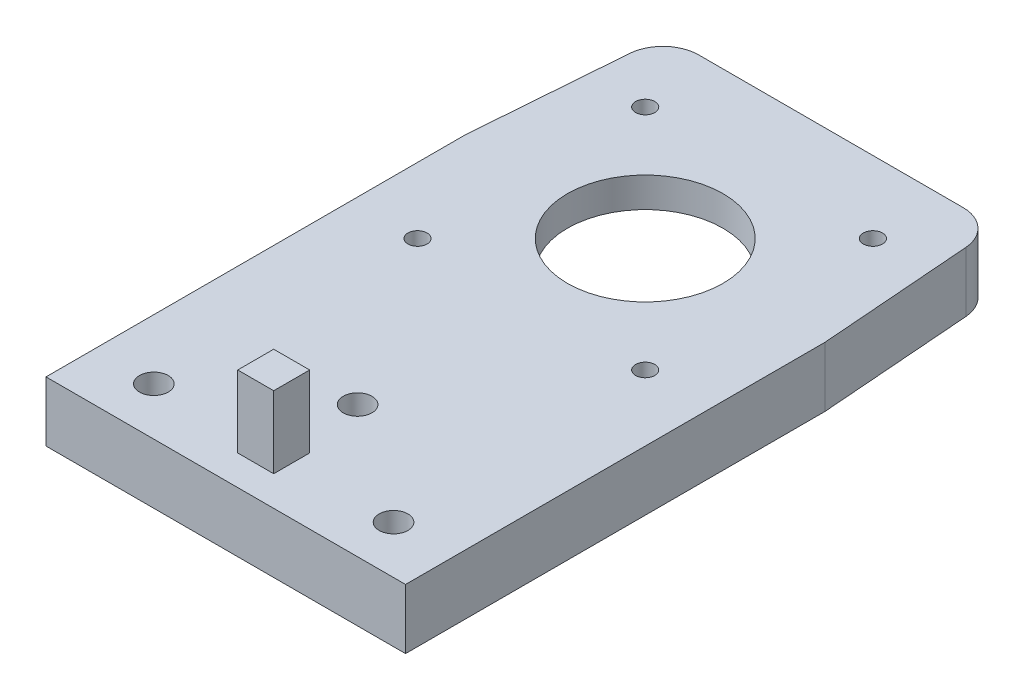
from build123d import *

# Parameters (mm, degrees)
BOSS_EXTRUDE1_DEPTH                                 = 5
CUT_EXTRUDE1_REACH                                  = 7
SKETCH2_R                                           = 6.4897
SKETCH3_W                                           = 3
SKETCH3_H                                           = 3
BOSS_EXTRUDE2_DEPTH                                 = 6
CSK_FOR_M2_COUNTERSUNK_FLAT_HEAD_SCREW1_D           = 2.4
CSK_FOR_M2_COUNTERSUNK_FLAT_HEAD_SCREW1_DEPTH       = 5.2
CSK_FOR_M2_COUNTERSUNK_FLAT_HEAD_SCREW1_CSINK_D     = 5.4
CSK_FOR_M2_COUNTERSUNK_FLAT_HEAD_SCREW1_CSINK_ANGLE = 90
CSK_FOR_M2_COUNTERSUNK_FLAT_HEAD_SCREW1_TIP         = 0.721032743
CUT_EXTRUDE2_DEPTH                                  = 2.5
FILLET1_R                                           = 3
M2_TAPPED_HOLE1_D                                   = 1.6
M2_TAPPED_HOLE1_DEPTH                               = 2.5


with BuildPart() as part:
    # Sketch1 → Boss-Extrude1 (new body)
    with BuildSketch(Plane(origin=(0, 0, 0), x_dir=(1, 0, 0), z_dir=(0, 1, 0))):
        Polygon((-15, 0), (15, 0), (15, 35), (13.807692308, 50.5), (-13.807692308, 50.5), (-15, 35), align=None)
    extrude(amount=BOSS_EXTRUDE1_DEPTH)

    # Sketch2 → Cut-Extrude1 (cut, up to next)
    with BuildSketch(Plane(origin=(0, 5, 0), x_dir=(1, 0, 0), z_dir=(0, 1, 0)), mode=Mode.PRIVATE) as cut_extrude1_sk1:
        with Locations((0, 35)):
            Circle(SKETCH2_R)
    cut_extrude1_tool1 = extrude(cut_extrude1_sk1.sketch, amount=-CUT_EXTRUDE1_REACH, mode=Mode.PRIVATE) & part.part
    add(cut_extrude1_tool1.solids().sort_by_distance((0, 5, -35))[0], mode=Mode.SUBTRACT)

    # Sketch3 → Boss-Extrude2 (add)
    with BuildSketch(Plane(origin=(0, 5, 0), x_dir=(1, 0, 0), z_dir=(0, 1, 0))):
        with Locations((0, 4)):
            Rectangle(SKETCH3_W, SKETCH3_H)
    extrude(amount=BOSS_EXTRUDE2_DEPTH)

    # CSK for M2 Countersunk Flat Head Screw1
    with Locations(Plane(origin=(0, 0, 0), x_dir=(-1, 0, 0), z_dir=(0, -1, 0))):
        with Locations((-10, 4), (10, 4), (0, 11)):
            CounterSinkHole(CSK_FOR_M2_COUNTERSUNK_FLAT_HEAD_SCREW1_D / 2, CSK_FOR_M2_COUNTERSUNK_FLAT_HEAD_SCREW1_CSINK_D / 2, depth=CSK_FOR_M2_COUNTERSUNK_FLAT_HEAD_SCREW1_DEPTH, counter_sink_angle=CSK_FOR_M2_COUNTERSUNK_FLAT_HEAD_SCREW1_CSINK_ANGLE)
            with Locations((0, 0, -(CSK_FOR_M2_COUNTERSUNK_FLAT_HEAD_SCREW1_DEPTH + CSK_FOR_M2_COUNTERSUNK_FLAT_HEAD_SCREW1_TIP / 2))):  # 118° drill point
                Cone(0, CSK_FOR_M2_COUNTERSUNK_FLAT_HEAD_SCREW1_D / 2, CSK_FOR_M2_COUNTERSUNK_FLAT_HEAD_SCREW1_TIP, mode=Mode.SUBTRACT)

    # Sketch6 → Cut-Extrude2 (cut)
    with BuildSketch(Plane.XZ):
        with BuildLine():
            Line((-10.5, -48), (10.5, -48))
            ThreePointArc((10.5, -48), (12.267766953, -47.267766953), (13, -45.5))
            Line((13, -45.5), (13, -24.5))
            ThreePointArc((13, -24.5), (12.267766953, -22.732233047), (10.5, -22))
            Line((10.5, -22), (-10.5, -22))
            ThreePointArc((-10.5, -22), (-12.267766953, -22.732233047), (-13, -24.5))
            Line((-13, -24.5), (-13, -45.5))
            ThreePointArc((-13, -45.5), (-12.267766953, -47.267766953), (-10.5, -48))
        make_face()
    extrude(amount=-CUT_EXTRUDE2_DEPTH, mode=Mode.SUBTRACT)

    # Fillet1
    fillet1_edges = [part.edges().sort_by_distance(p)[0] for p in [
        (-13.807692308, 2.5, -50.5),
        (13.807692308, 2.5, -50.5),
    ]]
    fillet(fillet1_edges, radius=FILLET1_R)

    # M2 Tapped Hole1
    with Locations(Plane(origin=(0, 2.5, 0), x_dir=(-1, 0, 0), z_dir=(0, -1, 0))):
        with Locations((9.5, 25.5), (9.5, 44.5), (-9.5, 44.5), (-9.5, 25.5)):
            Hole(M2_TAPPED_HOLE1_D / 2, depth=M2_TAPPED_HOLE1_DEPTH)


solid = part.part
